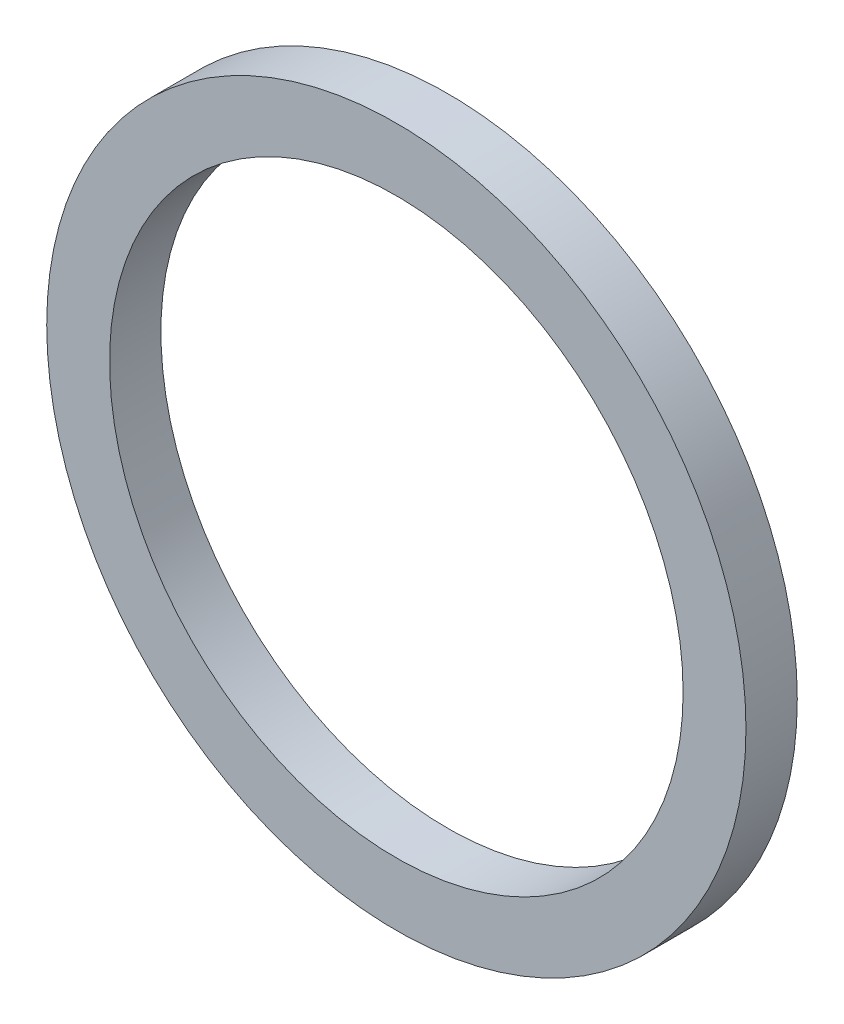
from build123d import *

# Parameters (mm, degrees)
SKETCH1_R           = 133.5
SKETCH1_R_2         = 109.5
BOSS_EXTRUDE1_DEPTH = 19.6


with BuildPart() as part:
    # Sketch1 → Boss-Extrude1 (new body)
    with BuildSketch(Plane.XY):
        Circle(SKETCH1_R)
        Circle(SKETCH1_R_2, mode=Mode.SUBTRACT)
    extrude(amount=BOSS_EXTRUDE1_DEPTH)


solid = part.part
